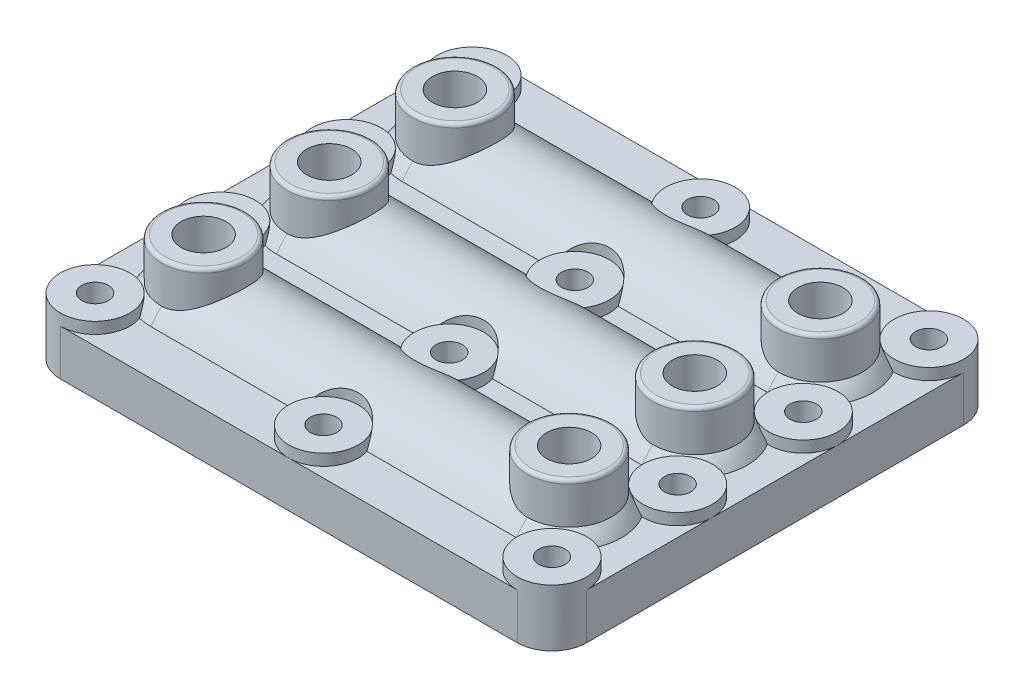
from build123d import *
from build123d.topology import SkipClean

# Parameters (mm, degrees)
BOSS_EXTRUDE1_DEPTH     = 1.5875
BOSS_EXTRUDE2_DEPTH     = 4.7625
INLET_OUTLET_POSTS_R    = 5.842
BOSS_EXTRUDE4_DEPTH     = 13.7795
REVOLVE2_ANGLE          = 180
LPATTERN1_COUNT         = 3
LPATTERN1_PITCH         = 17.4625
SKETCH22_R              = 4.826
BOSS_EXTRUDE5_DEPTH     = 1.5875
SKETCH23_R              = 4.826
CUT_EXTRUDE3_DEPTH      = 49.611033581
SKETCH24_R              = 1.8415
CUT_EXTRUDE4_DEPTH      = 49.611033581
SKETCH19_R              = 3.1242
CUT_EXTRUDE2_DEPTH      = 5.842
CUT_EXTRUDE1_DEPTH      = 0.93218
CUT_REVOLVE7_ANGLE      = 180
LPATTERN6_COUNT         = 3
LPATTERN6_PITCH         = 17.4625
SKETCH14_R              = 1.5875
CUT_REVOLVE8_ANGLE      = 90
LPATTERN7_COUNT         = 3
LPATTERN7_PITCH         = 17.4625
MIRROR1_COPY_1_SKETCH_R = 1.5875
MIRROR1_COPY_1_ANGLE    = 90
MIRROR1_COPY_2_SKETCH_R = 1.5875
MIRROR1_COPY_2_ANGLE    = 90
MIRROR1_COPY_3_SKETCH_R = 1.5875
MIRROR1_COPY_3_ANGLE    = 90
FILLET1_R               = 0.508
LPATTERN8_COUNT         = 3
LPATTERN8_PITCH         = 17.4625


with BuildPart() as part:
    # Footprint B → Boss-Extrude1 (new body)
    with BuildSketch(Plane(origin=(0, 0, 0), x_dir=(1, 0, 0), z_dir=(0, 1, 0))):
        with BuildLine():
            Line((31.75, 31.01975), (-31.75, 31.01975))
            ThreePointArc((-31.75, 31.01975), (-35.162497326, 29.606247326), (-36.576, 26.19375))
            Line((-36.576, 26.19375), (-36.576, -26.19375))
            ThreePointArc((-36.576, -26.19375), (-35.162497326, -29.606247326), (-31.75, -31.01975))
            Line((-31.75, -31.01975), (31.75, -31.01975))
            ThreePointArc((31.75, -31.01975), (35.162497326, -29.606247326), (36.576, -26.19375))
            Line((36.576, -26.19375), (36.576, 26.19375))
            ThreePointArc((36.576, 26.19375), (35.162497326, 29.606247326), (31.75, 31.01975))
        make_face()
    extrude(amount=BOSS_EXTRUDE1_DEPTH)

    # Main Body A → Boss-Extrude2 (add)
    with BuildSketch(Plane(origin=(0, 1.5875, 0), x_dir=(1, 0, 0), z_dir=(0, 1, 0))):
        with BuildLine():
            Line((-36.576, 26.19375), (-36.576, -26.19375))
            ThreePointArc((-36.576, -26.19375), (-35.162497326, -29.606247326), (-31.75, -31.01975))
            Line((-31.75, -31.01975), (31.75, -31.01975))
            ThreePointArc((31.75, -31.01975), (35.162497326, -29.606247326), (36.576, -26.19375))
            Line((36.576, -26.19375), (36.576, 26.19375))
            ThreePointArc((36.576, 26.19375), (35.162497326, 29.606247326), (31.75, 31.01975))
            Line((31.75, 31.01975), (-31.75, 31.01975))
            ThreePointArc((-31.75, 31.01975), (-35.162497326, 29.606247326), (-36.576, 26.19375))
        make_face()
    extrude(amount=BOSS_EXTRUDE2_DEPTH)

    # Inlet_outlet posts → Boss-Extrude4 (add)
    with BuildSketch(Plane(origin=(0, 0, 0), x_dir=(1, 0, 0), z_dir=(0, 1, 0))):
        with Locations((25.4, 17.4625)):
            Circle(INLET_OUTLET_POSTS_R)
        with Locations((25.4, 0)):
            Circle(INLET_OUTLET_POSTS_R)
        with Locations((25.4, -17.4625)):
            Circle(INLET_OUTLET_POSTS_R)
        with Locations((-25.4, -17.4625)):
            Circle(INLET_OUTLET_POSTS_R)
        with Locations((-25.4, 0)):
            Circle(INLET_OUTLET_POSTS_R)
        with Locations((-25.4, 17.4625)):
            Circle(INLET_OUTLET_POSTS_R)
    extrude(amount=BOSS_EXTRUDE4_DEPTH)

    # Sketch21 → Revolve2 (revolve)
    with BuildSketch(Plane(origin=(0, 1.5875, 0), x_dir=(-1, 0, 0), z_dir=(0, 1, 0))):
        with BuildLine():
            Line((25.4, -8.73125), (-25.4, -8.73125))
            ThreePointArc((-25.4, -8.73125), (-31.573926083, -11.288573917), (-34.13125, -17.4625))
            Line((-34.13125, -17.4625), (34.13125, -17.4625))
            ThreePointArc((34.13125, -17.4625), (31.573926083, -11.288573917), (25.4, -8.73125))
        make_face()
    revolve2 = revolve(axis=Axis((41.047323499, 1.5875, -17.4625), (-1, 0, 0)), revolution_arc=REVOLVE2_ANGLE)

    # LPattern1: Revolve2 ×3
    with Locations(*[(0, 0, i * LPATTERN1_PITCH) for i in range(1, LPATTERN1_COUNT)]):
        add(revolve2)

    # Sketch22 → Boss-Extrude5 (add)
    with SkipClean():  # the faces are left unmerged after this step: merging them gives an invalid solid
        with BuildSketch(Plane(origin=(0, 6.35, 0), x_dir=(1, 0, 0), z_dir=(0, 1, 0))):
            with Locations((-31.75, 26.19375)):
                Circle(SKETCH22_R)
            with Locations((-31.75, 8.73125)):
                Circle(SKETCH22_R)
            with Locations((-31.75, -8.73125)):
                Circle(SKETCH22_R)
            with Locations((-31.75, -26.19375)):
                Circle(SKETCH22_R)
            with Locations((0, -26.19375)):
                Circle(SKETCH22_R)
            with Locations((0, -8.73125)):
                Circle(SKETCH22_R)
            with Locations((0, 8.73125)):
                Circle(SKETCH22_R)
            with Locations((0, 26.19375)):
                Circle(SKETCH22_R)
            with Locations((31.75, 26.19375)):
                Circle(SKETCH22_R)
            with Locations((31.75, 8.73125)):
                Circle(SKETCH22_R)
            with Locations((31.75, -8.73125)):
                Circle(SKETCH22_R)
            with Locations((31.75, -26.19375)):
                Circle(SKETCH22_R)
        extrude(amount=BOSS_EXTRUDE5_DEPTH)

    # Sketch23 → Cut-Extrude3 (cut, through all)
    with SkipClean():  # the faces are left unmerged after this step: merging them gives an invalid solid
        with BuildSketch(Plane(origin=(0, 7.9375, 0), x_dir=(1, 0, 0), z_dir=(0, 1, 0))):
            with Locations((0, -26.19375)):
                Circle(SKETCH23_R)
            with Locations((0, -8.73125)):
                Circle(SKETCH23_R)
            with Locations((0, 8.73125)):
                Circle(SKETCH23_R)
            with Locations((0, 26.19375)):
                Circle(SKETCH23_R)
        extrude(amount=CUT_EXTRUDE3_DEPTH, mode=Mode.SUBTRACT)

    # Sketch24 → Cut-Extrude4 (cut, through all)
    with SkipClean():  # the faces are left unmerged after this step: merging them gives an invalid solid
        with BuildSketch(Plane(origin=(0, 7.9375, 0), x_dir=(1, 0, 0), z_dir=(0, 1, 0))):
            with Locations((-31.75, 26.19375)):
                Circle(SKETCH24_R)
            with Locations((-31.75, 8.73125)):
                Circle(SKETCH24_R)
            with Locations((-31.75, -8.73125)):
                Circle(SKETCH24_R)
            with Locations((-31.75, -26.19375)):
                Circle(SKETCH24_R)
            with Locations((0, 26.19375)):
                Circle(SKETCH24_R)
            with Locations((0, 8.73125)):
                Circle(SKETCH24_R)
            with Locations((0, -8.73125)):
                Circle(SKETCH24_R)
            with Locations((0, -26.19375)):
                Circle(SKETCH24_R)
            with Locations((31.75, 26.19375)):
                Circle(SKETCH24_R)
            with Locations((31.75, 8.73125)):
                Circle(SKETCH24_R)
            with Locations((31.75, -8.73125)):
                Circle(SKETCH24_R)
            with Locations((31.75, -26.19375)):
                Circle(SKETCH24_R)
        extrude(amount=-CUT_EXTRUDE4_DEPTH, mode=Mode.SUBTRACT)

    # Sketch19 → Cut-Extrude2 (cut)
    with SkipClean():  # the faces are left unmerged after this step: merging them gives an invalid solid
        with BuildSketch(Plane(origin=(0, 13.7795, 0), x_dir=(1, 0, 0), z_dir=(0, 1, 0))):
            with Locations((-25.4, 17.4625)):
                Circle(SKETCH19_R)
            with Locations((-25.4, 0)):
                Circle(SKETCH19_R)
            with Locations((-25.4, -17.4625)):
                Circle(SKETCH19_R)
            with Locations((25.4, 17.4625)):
                Circle(SKETCH19_R)
            with Locations((25.4, 0)):
                Circle(SKETCH19_R)
            with Locations((25.4, -17.4625)):
                Circle(SKETCH19_R)
        extrude(amount=-CUT_EXTRUDE2_DEPTH, mode=Mode.SUBTRACT)

    # Gas Channel → Cut-Extrude1 (cut)
    with SkipClean():  # the faces are left unmerged after this step: merging them gives an invalid solid
        with BuildSketch(Plane(origin=(0, 0, 0), x_dir=(1, 0, 0), z_dir=(0, 1, 0))):
            with BuildLine():
                Line((-19.05, 19.70756403), (19.05, 19.70756403))
                ThreePointArc((19.05, 19.70756403), (21.29506403, 17.4625), (19.05, 15.21743597))
                Line((19.05, 15.21743597), (-19.05, 15.21743597))
                ThreePointArc((-19.05, 15.21743597), (-21.29506403, 17.4625), (-19.05, 19.70756403))
            make_face()
        cut_extrude1 = extrude(amount=CUT_EXTRUDE1_DEPTH, mode=Mode.SUBTRACT)

    # Sketch13 → Cut-Revolve7 (revolve, cut)
    with SkipClean():  # the faces are left unmerged after this step: merging them gives an invalid solid
        with BuildSketch(Plane.XZ.offset(-0.93218)):
            with BuildLine():
                Line((-19.05, -19.70756403), (19.05, -19.70756403))
                ThreePointArc((19.05, -19.70756403), (20.6375, -19.05), (21.29506403, -17.4625))
                Line((21.29506403, -17.4625), (-21.29506403, -17.4625))
                ThreePointArc((-21.29506403, -17.4625), (-20.6375, -19.05), (-19.05, -19.70756403))
            make_face()
        cut_revolve7 = revolve(axis=Axis((-22.011141991, 0.93218, -17.4625), (1, 0, 0)), revolution_arc=CUT_REVOLVE7_ANGLE, mode=Mode.SUBTRACT)

    # LPattern6: Cut-Extrude1, Cut-Revolve7 ×3
    with SkipClean():  # the faces are left unmerged after this step: merging them gives an invalid solid
        with Locations(*[(0, 0, i * LPATTERN6_PITCH) for i in range(1, LPATTERN6_COUNT)]):
            add(cut_extrude1, mode=Mode.SUBTRACT)
            add(cut_revolve7, mode=Mode.SUBTRACT)

    # Sketch14 → Cut-Revolve8 (revolve, cut)
    with SkipClean():  # the faces are left unmerged after this step: merging them gives an invalid solid
        with BuildSketch(Plane(origin=(19.05, 0, 0), x_dir=(0, 0, -1), z_dir=(1, 0, 0))):
            with Locations((17.4625, 1.5875)):
                Circle(SKETCH14_R)
        cut_revolve8 = revolve(axis=Axis((19.05, 7.9375, -12.915188309), (0, 0, 1)), revolution_arc=CUT_REVOLVE8_ANGLE, mode=Mode.SUBTRACT)

    # LPattern7: Cut-Revolve8 ×3
    with SkipClean():  # the faces are left unmerged after this step: merging them gives an invalid solid
        with Locations(*[(0, 0, i * LPATTERN7_PITCH) for i in range(1, LPATTERN7_COUNT)]):
            add(cut_revolve8, mode=Mode.SUBTRACT)

    # Mirror1 copy 1 sketch → Mirror1 copy 1 (revolve, cut)
    with SkipClean():  # the faces are left unmerged after this step: merging them gives an invalid solid
        with BuildSketch(Plane(origin=(-19.05, 0, 17.4625), x_dir=(0, 0, -1), z_dir=(-1, 0, 0))):
            with Locations((17.4625, -1.5875)):
                Circle(MIRROR1_COPY_1_SKETCH_R)
        revolve(axis=Axis((-19.05, 7.9375, 4.547311691), (0, 0, -1)), revolution_arc=MIRROR1_COPY_1_ANGLE, mode=Mode.SUBTRACT)

    # Mirror1 copy 2 sketch → Mirror1 copy 2 (revolve, cut)
    with SkipClean():  # the faces are left unmerged after this step: merging them gives an invalid solid
        with BuildSketch(Plane(origin=(-19.05, 0, 34.925), x_dir=(0, 0, -1), z_dir=(-1, 0, 0))):
            with Locations((17.4625, -1.5875)):
                Circle(MIRROR1_COPY_2_SKETCH_R)
        revolve(axis=Axis((-19.05, 7.9375, 22.009811691), (0, 0, -1)), revolution_arc=MIRROR1_COPY_2_ANGLE, mode=Mode.SUBTRACT)

    # Mirror1 copy 3 sketch → Mirror1 copy 3 (revolve, cut)
    with SkipClean():  # the faces are left unmerged after this step: merging them gives an invalid solid
        with BuildSketch(Plane(origin=(-19.05, 0, 0), x_dir=(0, 0, -1), z_dir=(-1, 0, 0))):
            with Locations((17.4625, -1.5875)):
                Circle(MIRROR1_COPY_3_SKETCH_R)
        revolve(axis=Axis((-19.05, 7.9375, -12.915188309), (0, 0, -1)), revolution_arc=MIRROR1_COPY_3_ANGLE, mode=Mode.SUBTRACT)

    # Fillet1
    fillet1_edges = [part.edges().sort_by_distance(p)[0] for p in [
        (19.558, 13.7795, 17.4625),
        (-31.242, 13.7795, 17.4625),
        (-31.242, 13.7795, 0),
        (19.558, 13.7795, 0),
        (19.558, 13.7795, -17.4625),
        (-31.242, 13.7795, -17.4625),
    ]]
    fillet(fillet1_edges, radius=FILLET1_R)

    # Cut-Sweep1: sweep along a path in Sketch25
    with SkipClean():  # the faces are left unmerged after this step: merging them gives an invalid solid
        with BuildLine(Plane.XZ) as cut_sweep1_path:
            Line((-23.53056, -12.672842985), (23.53056, -12.672842985))
            ThreePointArc((23.53056, -12.672842985), (28.320217015, -17.4625), (23.53056, -22.252157015))
            Line((23.53056, -22.252157015), (-23.53056, -22.252157015))
            ThreePointArc((-23.53056, -22.252157015), (-28.320217015, -17.4625), (-23.53056, -12.672842985))
        # Sketch27 → Cut-Sweep1 (sweep, cut)
        with BuildSketch(Plane(origin=(0, 0, 0), x_dir=(0, 0, -1), z_dir=(1, 0, 0))):
            with BuildLine():
                Line((13.561842985, -0.498676329), (12.672842985, -0.498676329))
                Line((12.672842985, -0.498676329), (12.672842985, 0.390323671))
                ThreePointArc((12.672842985, 0.390323671), (14.190460913, 1.018941599), (13.561842985, -0.498676329))
            make_face()
        cut_sweep1 = sweep(path=cut_sweep1_path.line, mode=Mode.SUBTRACT)

    # LPattern8: Cut-Sweep1 ×3
    with SkipClean():  # the faces are left unmerged after this step: merging them gives an invalid solid
        with Locations(*[(0, 0, i * LPATTERN8_PITCH) for i in range(1, LPATTERN8_COUNT)]):
            add(cut_sweep1, mode=Mode.SUBTRACT)


solid = part.part
